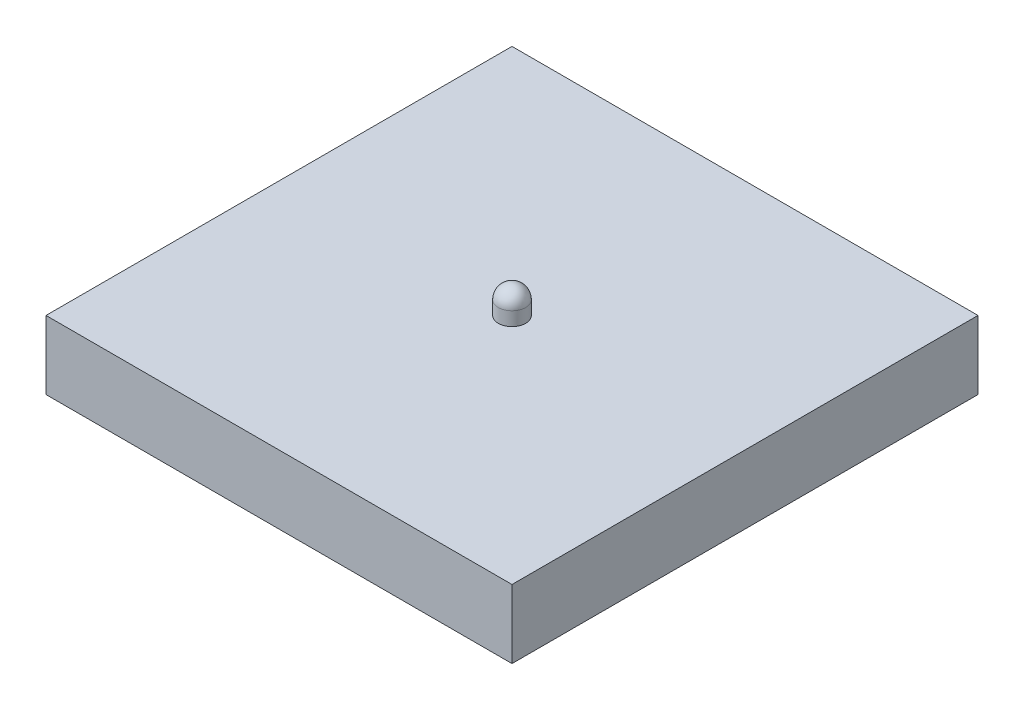
from build123d import *

# Parameters (mm, degrees)
SKETCH2_W           = 34
SKETCH2_H           = 34
BOSS_EXTRUDE1_DEPTH = 5
SKETCH3_W           = 32
SKETCH3_H           = 32
CUT_EXTRUDE1_DEPTH  = 3
SKETCH4_R           = 1
BOSS_EXTRUDE2_DEPTH = 2
FILLET1_R           = 1


with BuildPart() as part:
    # Sketch2 → Boss-Extrude1 (new body)
    with BuildSketch(Plane(origin=(0, 0, 0), x_dir=(1, 0, 0), z_dir=(0, 1, 0))):
        Rectangle(SKETCH2_W, SKETCH2_H)
    extrude(amount=BOSS_EXTRUDE1_DEPTH)

    # Sketch3 → Cut-Extrude1 (cut)
    with BuildSketch(Plane.XZ):
        Rectangle(SKETCH3_W, SKETCH3_H)
    extrude(amount=-CUT_EXTRUDE1_DEPTH, mode=Mode.SUBTRACT)

    # Sketch4 → Boss-Extrude2 (add)
    with BuildSketch(Plane(origin=(0, 5, 0), x_dir=(1, 0, 0), z_dir=(0, 1, 0))):
        Circle(SKETCH4_R)
    extrude(amount=BOSS_EXTRUDE2_DEPTH)

    # Fillet1
    fillet1_edges = [part.edges().sort_by_distance(p)[0] for p in [
        (-1, 7, 0),
    ]]
    fillet(fillet1_edges, radius=FILLET1_R)


solid = part.part
